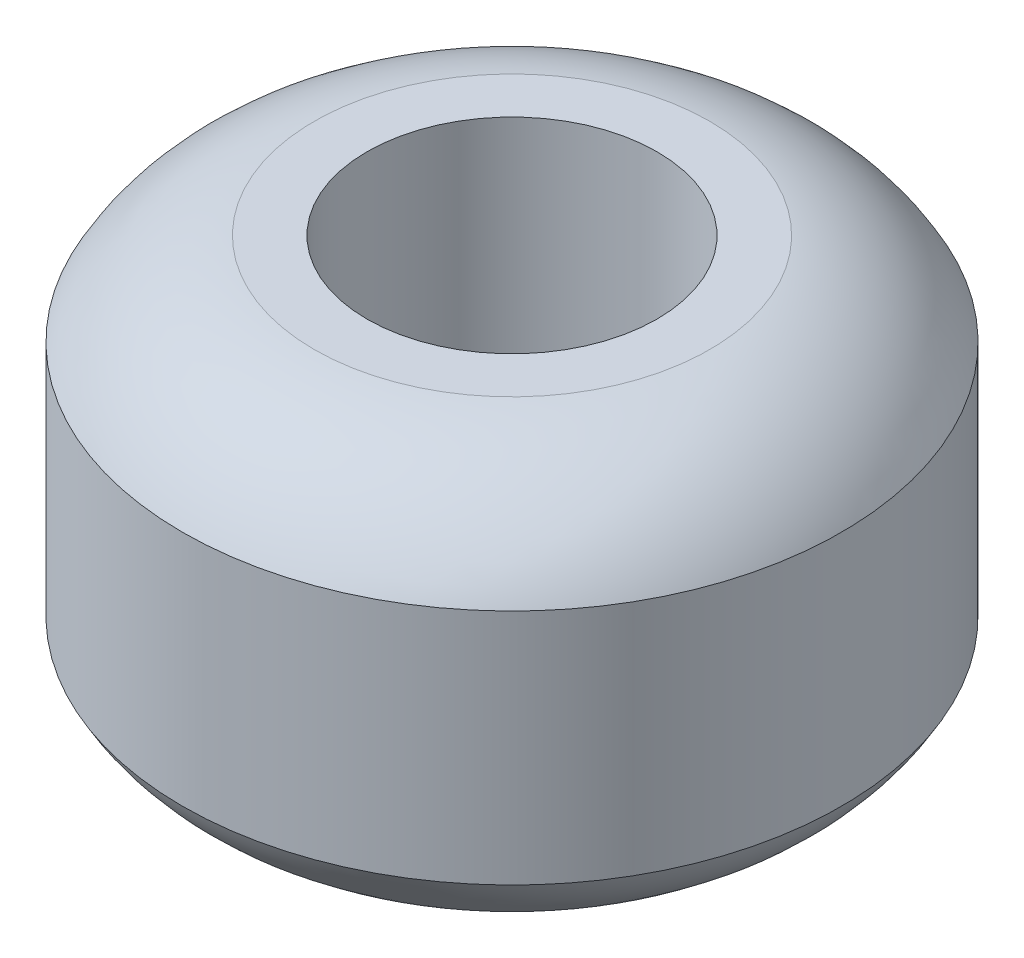
from build123d import *


with BuildPart() as part:
    # Sketch2 → Revolve1 (revolve)
    with BuildSketch(Plane.XY):
        with BuildLine():
            Line((11, 16), (11, -16))
            Line((11, -16), (15, -16))
            ThreePointArc((15, -16), (20.834787443, -13.69255349), (25, -9))
            Line((25, -9), (25, 9))
            ThreePointArc((25, 9), (20.834787443, 13.69255349), (15, 16))
            Line((15, 16), (11, 16))
        make_face()
    revolve(axis=Axis((0, 0, 0), (0, -1, 0)))


solid = part.part
